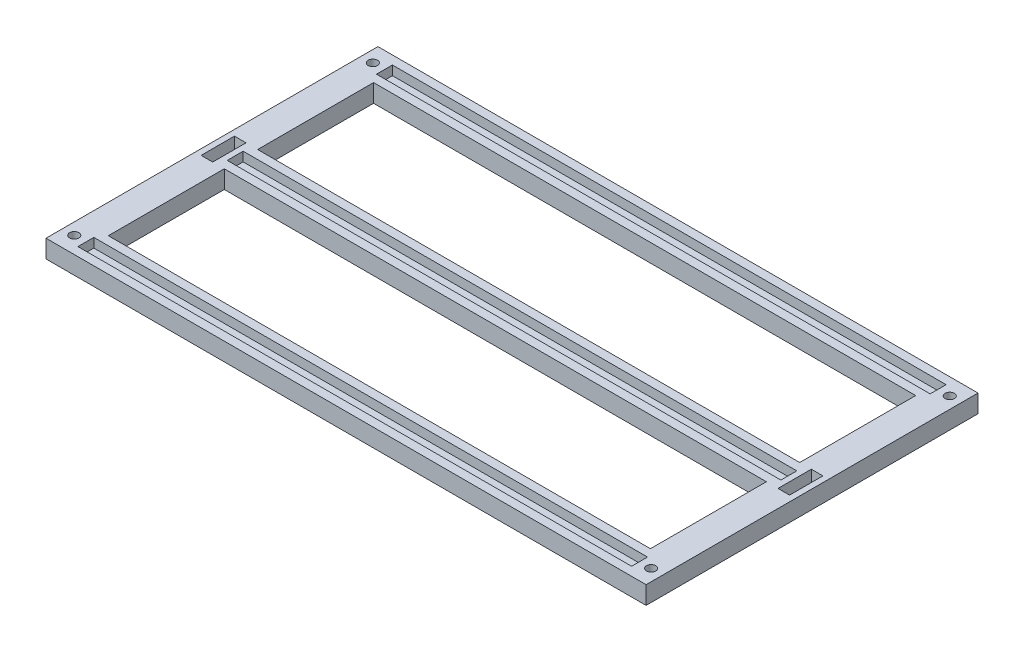
from build123d import *

# Parameters (mm, degrees)
SKETCH1_W           = 207
SKETCH1_H           = 114.5
SKETCH1_W_2         = 187
SKETCH1_H_2         = 40
SKETCH1_W_3         = 191
SKETCH1_H_3         = 5.5
SKETCH1_R           = 1.6
SKETCH1_W_4         = 4
SKETCH1_H_4         = 11.5
BOSS_EXTRUDE1_DEPTH = 3.2
BOSS_EXTRUDE2_START = -3
SKETCH1_3_W         = 207
SKETCH1_3_H         = 114.5
SKETCH1_3_W_2       = 187
SKETCH1_3_H_2       = 40
SKETCH1_3_R         = 1.6
SKETCH1_3_W_3       = 4
SKETCH1_3_H_3       = 11.5
BOSS_EXTRUDE2_DEPTH = 3


with BuildPart() as part:
    # Sketch1 → Boss-Extrude1 (new body)
    with BuildSketch(Plane(origin=(0, 0, 0), x_dir=(1, 0, 0), z_dir=(0, 1, 0))):
        Rectangle(SKETCH1_W, SKETCH1_H)
        with Locations((0, 25.75)):
            Rectangle(SKETCH1_W_2, SKETCH1_H_2, mode=Mode.SUBTRACT)
        Polygon((-95.5, 2.75), (93.5, 2.75), (95.5, 2.75), (95.5, -2.75), (-95.5, -2.75), align=None, mode=Mode.SUBTRACT)
        with Locations((0, -25.75)):
            Rectangle(SKETCH1_W_2, SKETCH1_H_2, mode=Mode.SUBTRACT)
        with Locations((0, -51.5)):
            Rectangle(SKETCH1_W_3, SKETCH1_H_3, mode=Mode.SUBTRACT)
        with Locations((0, 51.5)):
            Rectangle(SKETCH1_W_3, SKETCH1_H_3, mode=Mode.SUBTRACT)
        with Locations((-99.5, -51.5)):
            Circle(SKETCH1_R, mode=Mode.SUBTRACT)
        with Locations((-99.5, 0)):
            Rectangle(SKETCH1_W_4, SKETCH1_H_4, mode=Mode.SUBTRACT)
        with Locations((-99.5, 51.5)):
            Circle(SKETCH1_R, mode=Mode.SUBTRACT)
        with Locations((99.5, -51.5)):
            Circle(SKETCH1_R, mode=Mode.SUBTRACT)
        with Locations((99.5, 0)):
            Rectangle(SKETCH1_W_4, SKETCH1_H_4, mode=Mode.SUBTRACT)
        with Locations((99.5, 51.5)):
            Circle(SKETCH1_R, mode=Mode.SUBTRACT)
    extrude(amount=BOSS_EXTRUDE1_DEPTH)

    # Sketch1_3 → Boss-Extrude2 (add)
    with BuildSketch(Plane(origin=(0, 0, 0), x_dir=(1, 0, 0), z_dir=(0, 1, 0)).offset(BOSS_EXTRUDE2_START)):
        Rectangle(SKETCH1_3_W, SKETCH1_3_H)
        with Locations((0, 25.75)):
            Rectangle(SKETCH1_3_W_2, SKETCH1_3_H_2, mode=Mode.SUBTRACT)
        with Locations((0, -25.75)):
            Rectangle(SKETCH1_3_W_2, SKETCH1_3_H_2, mode=Mode.SUBTRACT)
        with Locations((-99.5, -51.5)):
            Circle(SKETCH1_3_R, mode=Mode.SUBTRACT)
        with Locations((-99.5, 0)):
            Rectangle(SKETCH1_3_W_3, SKETCH1_3_H_3, mode=Mode.SUBTRACT)
        with Locations((-99.5, 51.5)):
            Circle(SKETCH1_3_R, mode=Mode.SUBTRACT)
        with Locations((99.5, 0)):
            Rectangle(SKETCH1_3_W_3, SKETCH1_3_H_3, mode=Mode.SUBTRACT)
        with Locations((99.5, -51.5)):
            Circle(SKETCH1_3_R, mode=Mode.SUBTRACT)
        with Locations((99.5, 51.5)):
            Circle(SKETCH1_3_R, mode=Mode.SUBTRACT)
    extrude(amount=BOSS_EXTRUDE2_DEPTH)


solid = part.part
